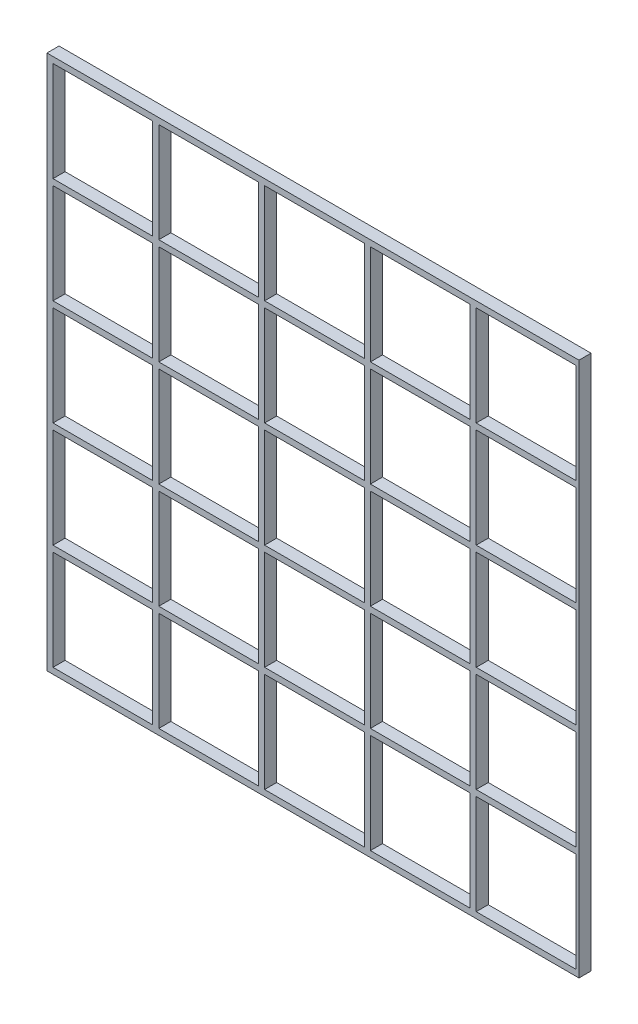
from build123d import *

# Parameters (mm, degrees)
CROQUIS1_W              = 37
CROQUIS1_H              = 37
CROQUIS1_W_2            = 33
CROQUIS1_H_2            = 33
SALIENTE_EXTRUIR1_DEPTH = 4
MATRIZL1_COUNT          = 5
MATRIZL1_PITCH          = 35
MATRIZL1_COUNT_DIR2     = 5
MATRIZL1_PITCH_DIR2     = 35
CROQUIS2_W              = 1
CROQUIS2_H              = 177
CORTAR_EXTRUIR1_DEPTH   = 10


with BuildPart() as part:
    # Croquis1 → Saliente-Extruir1 (new body)
    with BuildSketch(Plane.XY):
        with Locations((17.5, -17.5)):
            Rectangle(CROQUIS1_W, CROQUIS1_H)
        with Locations((17.5, -17.5)):
            Rectangle(CROQUIS1_W_2, CROQUIS1_H_2, mode=Mode.SUBTRACT)
    saliente_extruir1 = extrude(amount=SALIENTE_EXTRUIR1_DEPTH)

    # MatrizL1: Saliente-Extruir1 5 × 5
    with Locations(*[(-i * MATRIZL1_PITCH, j * MATRIZL1_PITCH_DIR2, 0) for i in range(MATRIZL1_COUNT) for j in range(MATRIZL1_COUNT_DIR2) if (i, j) != (0, 0)]):
        add(saliente_extruir1)

    # Croquis2 → Cortar-Extruir1 (cut)
    with BuildSketch(Plane.XY.offset(4)):
        with Locations((35.5, 52.5)):
            Rectangle(CROQUIS2_W, CROQUIS2_H)
    extrude(amount=-CORTAR_EXTRUIR1_DEPTH, mode=Mode.SUBTRACT)


solid = part.part
